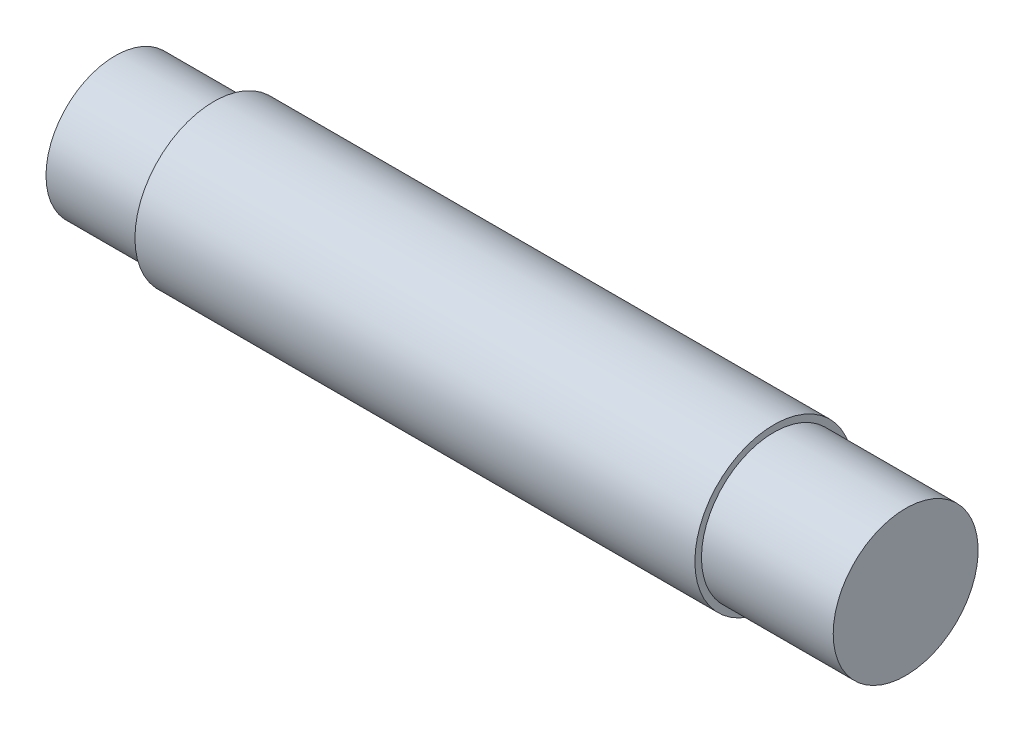
from build123d import *


with BuildPart() as part:
    # Sketch1 → Revolve1 (revolve)
    with BuildSketch(Plane.XY):
        Polygon((0, 0), (60, 0), (60, 5.5), (50, 5.5), (50, 6), (7.5, 6), (7.5, 5.25), (0, 5.25), align=None)
    revolve(axis=Axis((-6.166847311, 0, 0), (1, 0, 0)))


solid = part.part
